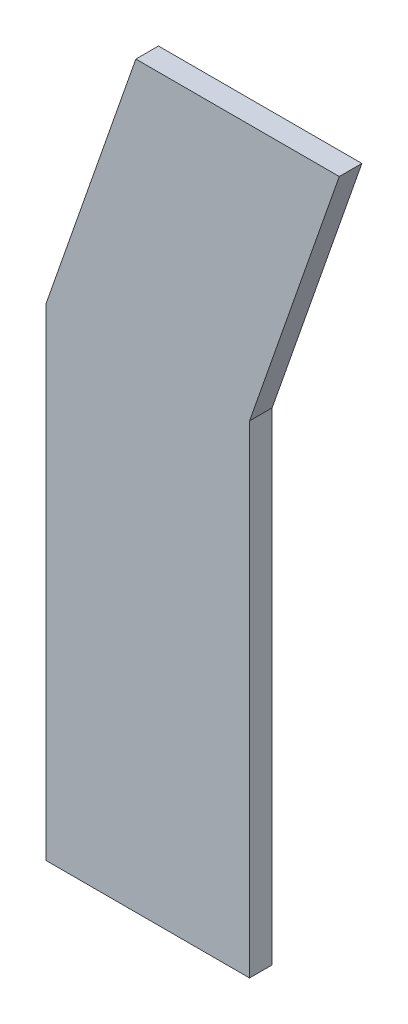
from build123d import *

# Parameters (mm, degrees)
BOSS_EXTRUDE1_DEPTH = 20


with BuildPart() as part:
    # Sketch1 → Boss-Extrude1 (new body)
    with BuildSketch(Plane.XY):
        Polygon((0, 0), (0, -426.89), (180, -426.89), (180, 0), (259.398855033, 226.981504278), (79.398855033, 226.981504278), align=None)
    extrude(amount=BOSS_EXTRUDE1_DEPTH)


solid = part.part
